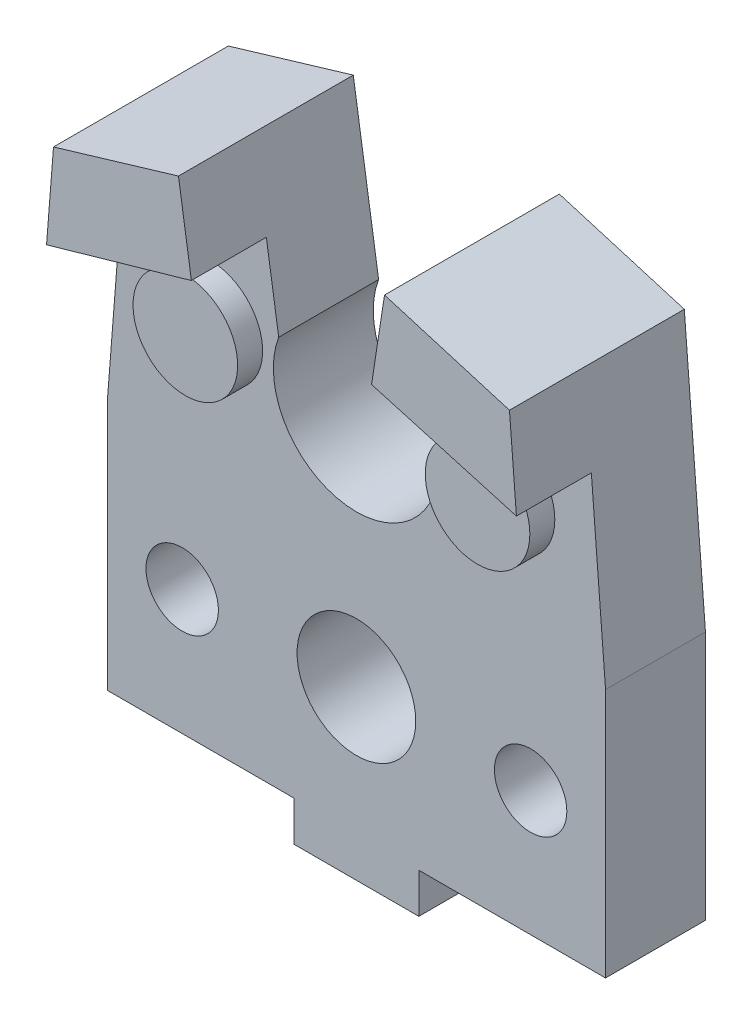
from build123d import *

# Parameters (mm, degrees)
BOSS_EXTRUDE1_DEPTH = 4
SKETCH2_W           = 5
SKETCH2_H           = 1.6
BOSS_EXTRUDE2_DEPTH = 4
SKETCH5_R           = 1.45
CUT_EXTRUDE3_DEPTH  = 14.2
SKETCH7_R           = 2.375
CUT_EXTRUDE6_DEPTH  = 15
SKETCH8_R           = 2.094517613
BOSS_EXTRUDE3_DEPTH = 1
BOSS_EXTRUDE4_DEPTH = 3


with BuildPart() as part:
    # Sketch1 → Boss-Extrude1 (new body)
    with BuildSketch(Plane.XY):
        with BuildLine():
            Line((-9.975, 0), (9.975, 0))
            Line((9.975, 0), (9.975, 10))
            Line((9.975, 10), (9.128095747, 20.764013839))
            Line((9.128095747, 20.764013839), (4.125144755, 22.256540984))
            Line((4.125144755, 22.256540984), (3.110466203, 15.675))
            ThreePointArc((3.110466203, 15.675), (0, 11.175), (-3.110466203, 15.675))
            Line((-3.110466203, 15.675), (-4.125144755, 22.256540984))
            Line((-4.125144755, 22.256540984), (-9.128095747, 20.764013839))
            Line((-9.128095747, 20.764013839), (-9.975, 10))
            Line((-9.975, 10), (-9.975, 0))
        make_face()
    extrude(amount=BOSS_EXTRUDE1_DEPTH)

    # Sketch2 → Boss-Extrude2 (add)
    with BuildSketch(Plane(origin=(0, 0, 0), x_dir=(-1, 0, 0), z_dir=(0, 0, -1))):
        with Locations((0, -0.8)):
            Rectangle(SKETCH2_W, SKETCH2_H)
    extrude(amount=-BOSS_EXTRUDE2_DEPTH)

    # Sketch5 → Cut-Extrude3 (cut)
    with BuildSketch(Plane.XY.offset(4)):
        with Locations((6.975, 5)):
            Circle(SKETCH5_R)
    cut_extrude3 = extrude(amount=-CUT_EXTRUDE3_DEPTH, mode=Mode.SUBTRACT)

    # Mirror1: Cut-Extrude3 across plane
    add(cut_extrude3.mirror(Plane(origin=(0, 0, 0), x_dir=(0, 0, 1), z_dir=(1, 0, 0))), mode=Mode.SUBTRACT)

    # Sketch7 → Cut-Extrude6 (cut)
    with BuildSketch(Plane.XY.offset(4)):
        with Locations((0, 5.1)):
            Circle(SKETCH7_R)
    extrude(amount=-CUT_EXTRUDE6_DEPTH, mode=Mode.SUBTRACT)

    # Sketch8 → Boss-Extrude3 (add)
    with BuildSketch(Plane.XY.offset(4)):
        with Locations((5.849630313, 14.875934422)):
            Circle(SKETCH8_R)
        with Locations(Location((-5.849630313, 14.875934422, 0), (0, 0, 180))):
            Circle(SKETCH8_R)
    extrude(amount=BOSS_EXTRUDE3_DEPTH)

    # Sketch9 → Boss-Extrude4 (add)
    with BuildSketch(Plane.XY.offset(4)):
        Polygon((4.125144755, 22.256540984), (3.606658762, 18.893469192), (9.406048413, 17.23128114), (9.128095747, 20.764013839), align=None)
        Polygon((-9.128095747, 20.764013839), (-4.125144755, 22.256540984), (-3.606658762, 18.893469192), (-9.406048413, 17.23128114), align=None)
    extrude(amount=BOSS_EXTRUDE4_DEPTH)


solid = part.part
